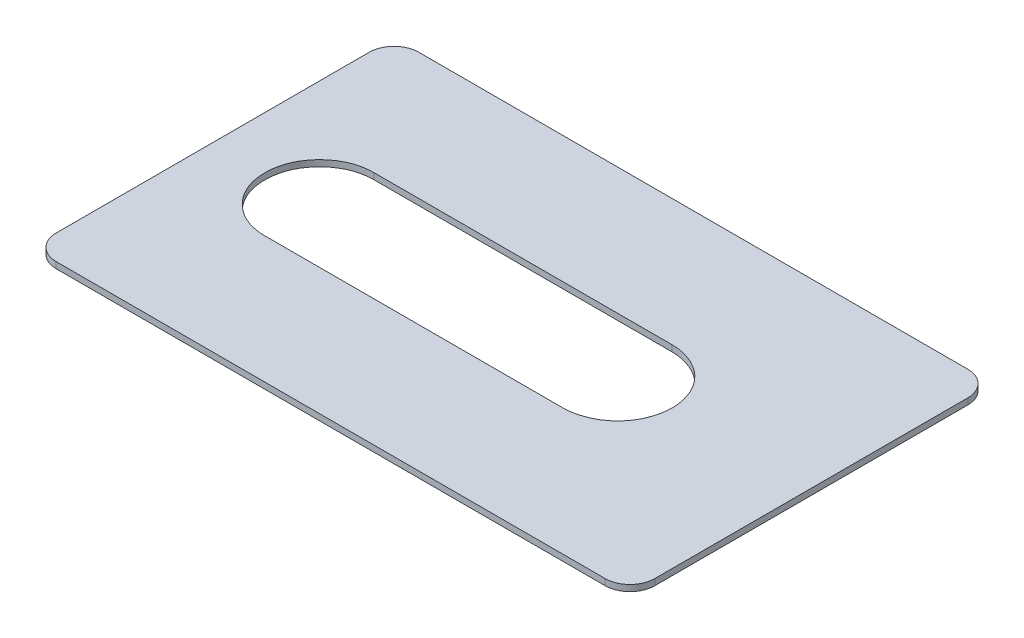
from build123d import *

# Parameters (mm, degrees)
BOSS_EXTRUDE1_DEPTH = 0.25


with BuildPart() as part:
    # Sketch1 → Boss-Extrude1 (new body)
    with BuildSketch(Plane(origin=(0, 0, 0), x_dir=(1, 0, 0), z_dir=(0, 1, 0))):
        with BuildLine():
            Line((12.799624508, 7.3), (-9.300375492, 7.3))
            ThreePointArc((-9.300375492, 7.3), (-10.007482273, 7.007106781), (-10.300375492, 6.3))
            Line((-10.300375492, 6.3), (-10.300375492, -6.3))
            ThreePointArc((-10.300375492, -6.3), (-10.007482273, -7.007106781), (-9.300375492, -7.3))
            Line((-9.300375492, -7.3), (12.799624508, -7.3))
            ThreePointArc((12.799624508, -7.3), (13.506731289, -7.007106781), (13.799624508, -6.3))
            Line((13.799624508, -6.3), (13.799624508, 6.3))
            ThreePointArc((13.799624508, 6.3), (13.506731289, 7.007106781), (12.799624508, 7.3))
        make_face()
        with BuildLine():
            Line((-6, 2.2), (6, 2.2))
            add(Edge.make_bspline(
                [(6, 2.2), (6.561292129, 2.2), (7.730716323, 1.723876992), (8.434682325, -7.8217e-05), (7.730554293, -1.724014124), (6.561245935, -2.2), (6, -2.2)],
                knots=[0, 0, 0, 0, 0.25, 0.5, 0.75, 1, 1, 1, 1], degree=3))
            Line((6, -2.2), (-6, -2.2))
            add(Edge.make_bspline(
                [(-6, -2.2), (-6.286632035, -2.2), (-6.870184339, -2.096470778), (-7.591774941, -1.592328061), (-8.096898813, -0.867652922), (-8.251698338, -0.000240671), (-8.096307718, 0.869143795), (-7.591951498, 1.592127779), (-6.869322234, 2.096528001), (-6.286463211, 2.2), (-6, 2.2)],
                knots=[0, 0, 0, 0, 0.125, 0.25, 0.375, 0.5, 0.625, 0.75, 0.875, 1, 1, 1, 1], degree=3))
        make_face(mode=Mode.SUBTRACT)
    extrude(amount=BOSS_EXTRUDE1_DEPTH)


solid = part.part
